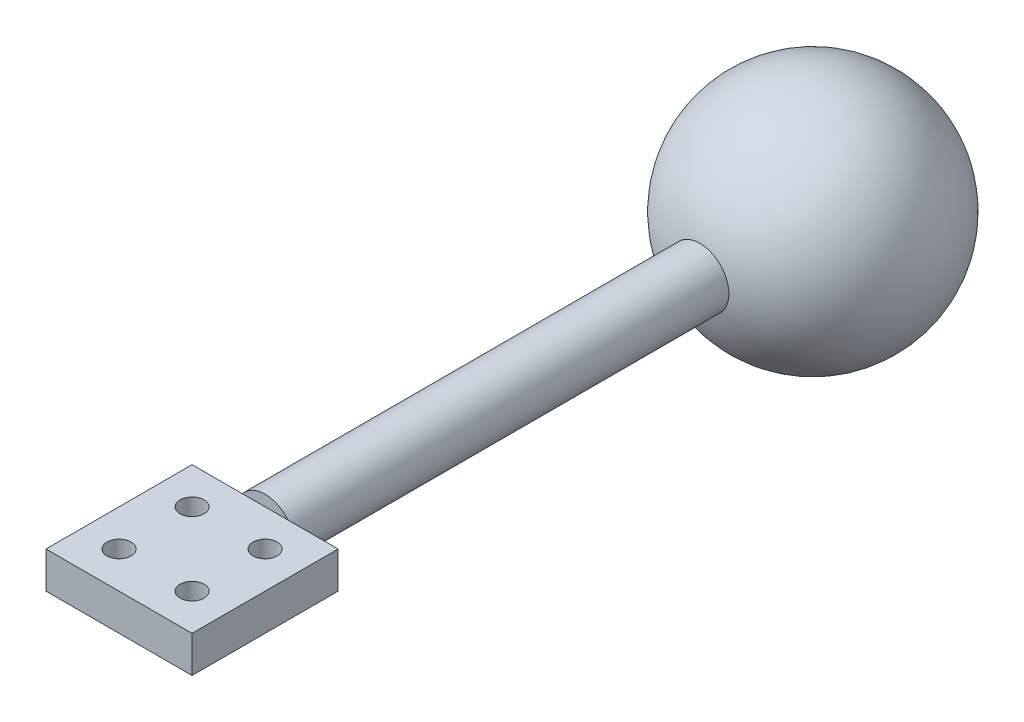
from build123d import *
from build123d.topology import SkipClean

# Parameters (mm, degrees)
SKETCH1_3_R              = 4
BOSS_EXTRUDE1_DEPTH      = 75
BOSS_EXTRUDE2_DEPTH      = 2.5
BOSS_EXTRUDE2_DEPTH_BACK = 2.5
SKETCH2_W                = 20
SKETCH2_H                = 20
SKETCH2_R                = 1.65


with BuildPart() as part:
    # Sketch1 one side → Revolve7 (revolve)
    with BuildSketch(Plane.XY):
        with BuildLine():
            ThreePointArc((0, -16), (11.313708499, -11.313708499), (16, 0))
            ThreePointArc((16, 0), (11.313708499, 11.313708499), (0, 16))
            Line((0, 16), (0, 4))
            ThreePointArc((0, 4), (2.828427125, 2.828427125), (4, 0))
            ThreePointArc((4, 0), (2.828427125, -2.828427125), (0, -4))
            Line((0, -4), (0, -16))
        make_face()
    revolve(axis=Axis((0, 16, 0), (0, -1, 0)))

    # Sketch1_3 → Boss-Extrude1 (add)
    with SkipClean():  # the faces are left unmerged after this step: merging them gives an invalid solid
        with BuildSketch(Plane.XY):
            Circle(SKETCH1_3_R)
        extrude(amount=BOSS_EXTRUDE1_DEPTH)

    # Sketch2 → Boss-Extrude2 (add, two sides: drawn at the far end of the back side and taken through both)
    with SkipClean():  # the faces are left unmerged after this step: merging them gives an invalid solid
        with BuildSketch(Plane(origin=(0, 0, 0), x_dir=(1, 0, 0), z_dir=(0, 1, 0)).offset(-BOSS_EXTRUDE2_DEPTH_BACK)):
            with Locations((0, -85)):
                Rectangle(SKETCH2_W, SKETCH2_H)
            with Locations((-5, -80)):
                Circle(SKETCH2_R, mode=Mode.SUBTRACT)
            with Locations((5, -80)):
                Circle(SKETCH2_R, mode=Mode.SUBTRACT)
            with Locations((5, -90)):
                Circle(SKETCH2_R, mode=Mode.SUBTRACT)
            with Locations((-5, -90)):
                Circle(SKETCH2_R, mode=Mode.SUBTRACT)
        extrude(amount=BOSS_EXTRUDE2_DEPTH + BOSS_EXTRUDE2_DEPTH_BACK)


solid = part.part
